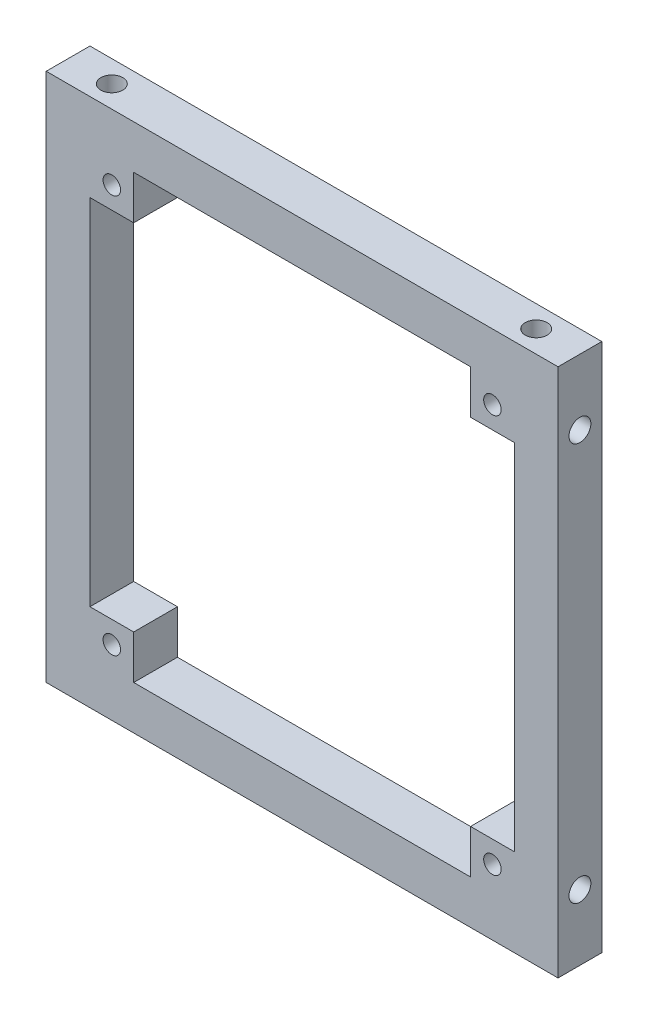
from build123d import *

# Parameters (mm, degrees)
SKETCH1_W          = 46.8
SKETCH1_H          = 48.4
SKETCH1_R          = 0.8
LEFT_PANEL_DEPTH   = 4
SKETCH9_R          = 1
CUT_EXTRUDE5_DEPTH = 4
SKETCH10_R         = 1
CUT_EXTRUDE6_DEPTH = 4
SKETCH11_R         = 1
CUT_EXTRUDE7_DEPTH = 4
SKETCH12_R         = 1
CUT_EXTRUDE8_DEPTH = 4


with BuildPart() as part:
    # Sketch1 → left_panel (new body)
    with BuildSketch(Plane.XY):
        with Locations((23.4, 24.2)):
            Rectangle(SKETCH1_W, SKETCH1_H)
        with Locations((6, 6)):
            Circle(SKETCH1_R, mode=Mode.SUBTRACT)
        with Locations((40.8, 6)):
            Circle(SKETCH1_R, mode=Mode.SUBTRACT)
        with Locations((40.8, 42.4)):
            Circle(SKETCH1_R, mode=Mode.SUBTRACT)
        with Locations((6, 42.4)):
            Circle(SKETCH1_R, mode=Mode.SUBTRACT)
        Polygon((8, 44.4), (38.8, 44.4), (38.8, 40.4), (42.8, 40.4), (42.8, 8), (38.8, 8), (38.8, 4), (8, 4), (8, 8), (4, 8), (4, 40.4), (8, 40.4), align=None, mode=Mode.SUBTRACT)
    extrude(amount=LEFT_PANEL_DEPTH)

    # Sketch9 → Cut-Extrude5 (cut)
    with BuildSketch(Plane(origin=(46.8, 0, 0), x_dir=(0, 0, -1), z_dir=(1, 0, 0))):
        with Locations((-2, 6)):
            Circle(SKETCH9_R)
        with Locations((-2, 42.4)):
            Circle(SKETCH9_R)
    extrude(amount=-CUT_EXTRUDE5_DEPTH, mode=Mode.SUBTRACT)

    # Sketch10 → Cut-Extrude6 (cut)
    with BuildSketch(Plane.ZY):
        with Locations((2, 6)):
            Circle(SKETCH10_R)
        with Locations((2, 42.4)):
            Circle(SKETCH10_R)
    extrude(amount=-CUT_EXTRUDE6_DEPTH, mode=Mode.SUBTRACT)

    # Sketch11 → Cut-Extrude7 (cut)
    with BuildSketch(Plane(origin=(0, 48.4, 0), x_dir=(1, 0, 0), z_dir=(0, 1, 0))):
        with Locations((4, -2)):
            Circle(SKETCH11_R)
        with Locations((42.8, -2)):
            Circle(SKETCH11_R)
    extrude(amount=-CUT_EXTRUDE7_DEPTH, mode=Mode.SUBTRACT)

    # Sketch12 → Cut-Extrude8 (cut)
    with BuildSketch(Plane.XZ):
        with Locations((4, 2)):
            Circle(SKETCH12_R)
        with Locations((42.8, 2)):
            Circle(SKETCH12_R)
    extrude(amount=-CUT_EXTRUDE8_DEPTH, mode=Mode.SUBTRACT)


solid = part.part
